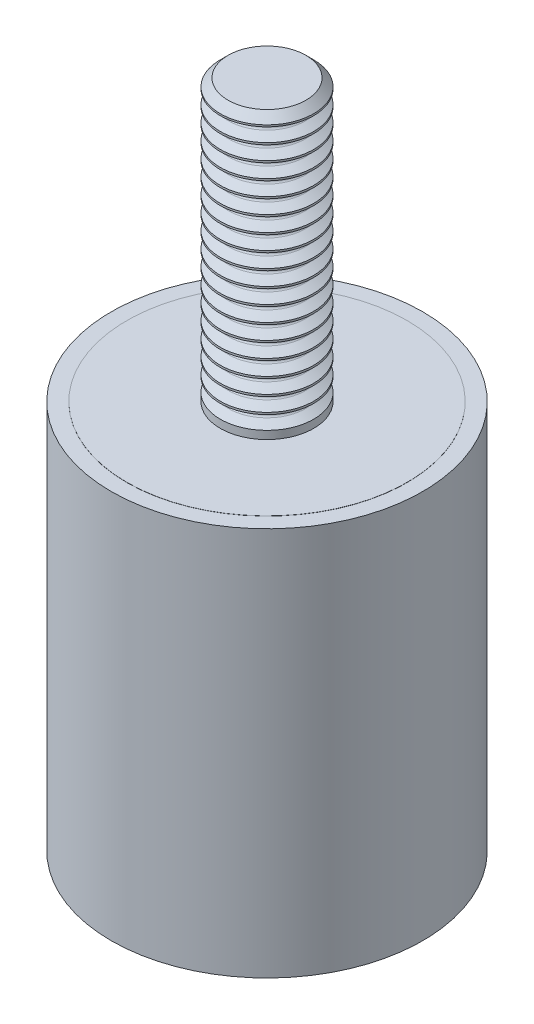
from build123d import *

# Parameters (mm, degrees)
CHAMFER1_SIZE         = 0.5
LPATTERN1_COUNT       = 17
LPATTERN1_PITCH       = 1
M6_TAPPED_HOLE1_D     = 5
M6_TAPPED_HOLE1_DEPTH = 10
M6_TAPPED_HOLE1_TIP   = 0.788246972


with BuildPart() as part:
    # Sketch1 → Revolve1 (revolve)
    with BuildSketch(Plane.XY):
        Polygon((0, 0), (9, 0), (9, 0.01), (10, 0.01), (10, 24.99), (9, 24.99), (9, 25), (3, 25), (3, 43), (0, 43), align=None)
    revolve(axis=Axis((0, 0, 0), (0, -1, 0)))

    # Chamfer1
    chamfer1_edges = [part.edges().sort_by_distance(p)[0] for p in [
        (-3, 43, 0),
    ]]
    chamfer(chamfer1_edges, length=CHAMFER1_SIZE)

    # Sketch2 → Cut-Revolve1 (revolve, cut)
    with BuildSketch(Plane.XY):
        with BuildLine():
            Line((3, 26.387823762), (2.4581665, 26.074996045))
            ThreePointArc((2.4581665, 26.074996045), (2.386, 25.95), (2.4581665, 25.825003955))
            Line((2.4581665, 25.825003955), (3, 25.512176238))
            Line((3, 25.512176238), (3, 26.387823762))
        make_face()
    cut_revolve1 = revolve(axis=Axis((0, 0, 0), (0, 1, 0)), mode=Mode.SUBTRACT)

    # LPattern1: Cut-Revolve1 ×17
    with Locations(*[(0, i * LPATTERN1_PITCH, 0) for i in range(1, LPATTERN1_COUNT)]):
        add(cut_revolve1, mode=Mode.SUBTRACT)

    # M6 Tapped Hole1
    with Locations(Plane(origin=(0, 0, 0), x_dir=(-1, 0, 0), z_dir=(0, -1, 0))):
        with Locations((0, 0)):
            Hole(M6_TAPPED_HOLE1_D / 2, depth=M6_TAPPED_HOLE1_DEPTH)
            with Locations((0, 0, -(M6_TAPPED_HOLE1_DEPTH + M6_TAPPED_HOLE1_TIP / 2))):  # 145° drill point
                Cone(0, M6_TAPPED_HOLE1_D / 2, M6_TAPPED_HOLE1_TIP, mode=Mode.SUBTRACT)

    # Sketch11 → Cut-Revolve3 (revolve, cut)
    with BuildSketch(Plane.XY):
        Polygon((0, 25), (0, 15.687823762), (3, 15.687823762), (3, 15.812176238), (2.4581665, 16.125003955), (2.4581665, 16.374996045), (3, 16.687823762), (3, 16.812176238), (2.4581665, 17.125003955), (2.4581665, 17.374996045), (3, 17.687823762), (3, 17.812176238), (2.4581665, 18.125003955), (2.4581665, 18.374996045), (3, 18.687823762), (3, 18.812176238), (2.4581665, 19.125003955), (2.4581665, 19.374996045), (3, 19.687823762), (3, 19.812176238), (2.4581665, 20.125003955), (2.4581665, 20.374996045), (3, 20.687823762), (3, 20.812176238), (2.4581665, 21.125003955), (2.4581665, 21.374996045), (3, 21.687823762), (3, 21.812176238), (2.4581665, 22.125003955), (2.4581665, 22.374996045), (3, 22.687823762), (3, 22.812176238), (2.4581665, 23.125003955), (2.4581665, 23.374996045), (3, 23.687823762), (3, 23.812176238), (2.4581665, 24.125003955), (2.4581665, 24.374996045), (3, 24.687823762), (3, 25), align=None)
    revolve(axis=Axis((0, 25, 0), (0, -1, 0)), mode=Mode.SUBTRACT)


with BuildPart() as cut_revolve3_piece_1:
    # of the separate pieces the step leaves, piece 1, a body of its own (cut_revolve3_pieces)
    add(part.part.solids().sort_by_distance((9, 25, 0))[0])


with BuildPart() as cut_revolve3_piece_2:
    # of the separate pieces the step leaves, piece 2, a body of its own (cut_revolve3_pieces)
    add(part.part.solids().sort_by_distance((3, 25.512176238, 0))[0])


solid = Compound([cut_revolve3_piece_1.part, cut_revolve3_piece_2.part])
